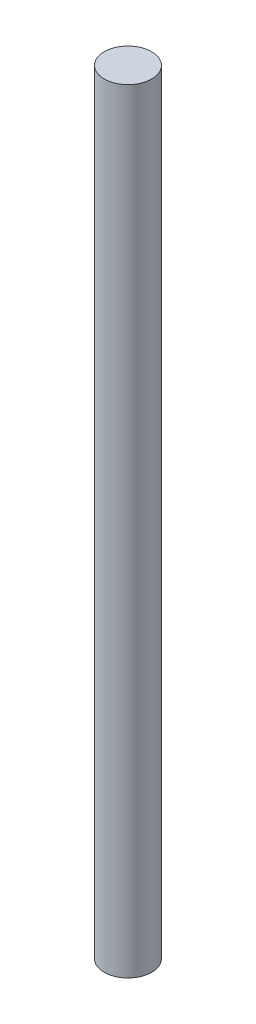
from build123d import *

# Parameters (mm, degrees)
SKETCH1_R           = 1.5
BOSS_EXTRUDE1_DEPTH = 24.5
SCALE1_SCALE        = 0.6


with BuildPart() as part:
    # Sketch1 → Boss-Extrude1 (new body, symmetric)
    with BuildSketch(Plane(origin=(0, 0, 0), x_dir=(1, 0, 0), z_dir=(0, 1, 0))):
        Circle(SKETCH1_R)
    extrude(amount=BOSS_EXTRUDE1_DEPTH, both=True)


with BuildPart() as part_1:
    # Scale1: scaled about (0, 0, 0)
    add(part.part.scale(SCALE1_SCALE))


solid = part_1.part
